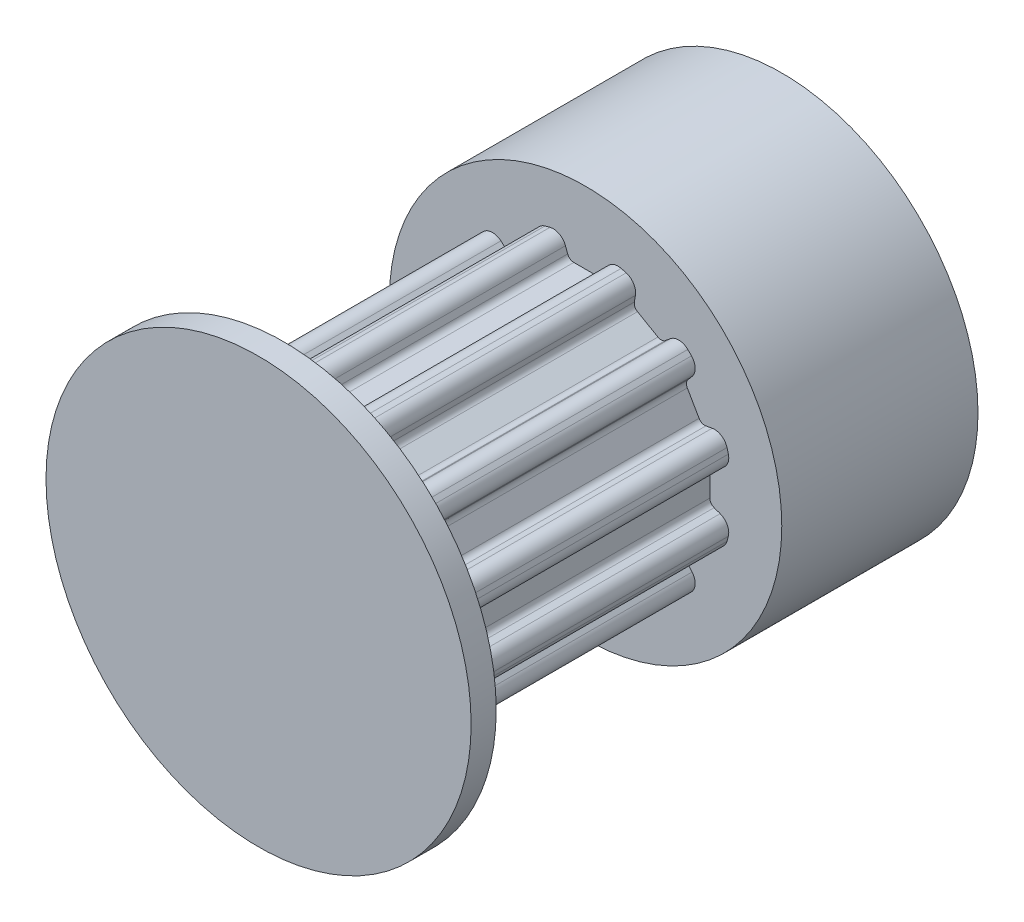
from build123d import *

# Parameters (mm, degrees)
SKETCH5_W           = 10
SKETCH5_H           = 4.5
SKETCH16_W          = 6
SKETCH16_H          = 6
CUT_TOOTH_DEPTH     = 10
PATTERN_TOOTH_COUNT = 12


with BuildPart() as part:
    # Sketch5 → body (revolve)
    with BuildSketch(Plane(origin=(0, 0, 0), x_dir=(0, 0, -1), z_dir=(1, 0, 0))):
        with Locations((5, 2.25)):
            Rectangle(SKETCH5_W, SKETCH5_H)
    revolve(axis=Axis((0, 0, 0), (0, 0, -1)))

    # Sketch16 → body-hub (revolve)
    with BuildSketch(Plane(origin=(0, 0, 0), x_dir=(0, 0, -1), z_dir=(1, 0, 0))):
        with Locations((13, 3)):
            Rectangle(SKETCH16_W, SKETCH16_H)
    revolve(axis=Axis((0, 0, -16), (0, 0, 1)))

    # Sketch23 → cut-tooth (cut)
    with BuildSketch(Plane.XY):
        with BuildLine():
            Line((0.547897017, 3.931595971), (0.6147699, 4.11532771))
            ThreePointArc((0.6147699, 4.11532771), (0.802803604, 4.331669589), (1.087295431, 4.366667911))
            Line((1.087295431, 4.366667911), (1.087295431, 4.933335822))
            Line((1.087295431, 4.933335822), (-1.087295431, 4.933335822))
            Line((-1.087295431, 4.933335822), (-1.087295431, 4.366667911))
            ThreePointArc((-1.087295431, 4.366667911), (-0.802803604, 4.331669589), (-0.6147699, 4.11532771))
            Line((-0.6147699, 4.11532771), (-0.547897017, 3.931595971))
            ThreePointArc((-0.547897017, 3.931595971), (-0.47467378, 3.836169591), (-0.359958492, 3.8))
            Line((-0.359958492, 3.8), (0.359958492, 3.8))
            ThreePointArc((0.359958492, 3.8), (0.47467378, 3.836169591), (0.547897017, 3.931595971))
        make_face()
    cut_tooth = extrude(amount=-CUT_TOOTH_DEPTH, mode=Mode.SUBTRACT)

    # pattern-tooth: cut-tooth ×12 about axis
    pattern_tooth_axis = Axis((0, 0, -10), (0, 0, 1))
    for i in range(1, PATTERN_TOOTH_COUNT):
        add(cut_tooth.rotate(pattern_tooth_axis, i * 360 / PATTERN_TOOTH_COUNT), mode=Mode.SUBTRACT)

    # Sketch25 → body-flange-front (revolve)
    with BuildSketch(Plane(origin=(0, 0, 0), x_dir=(0, 0, -1), z_dir=(1, 0, 0))):
        Polygon((1, 3.25), (0, 3.25), (0, 5.416666667), (0, 6.5), (1, 6.5), (1, 5.416666667), align=None)
    revolve(axis=Axis((0, 0, 0), (0, 0, -1)))

    # Sketch28 → body-flange-profile-front (revolve, cut)
    with BuildSketch(Plane(origin=(0, 0, 0), x_dir=(0, 0, -1), z_dir=(1, 0, 0))):
        Polygon((1, 6.5), (1, 6), (0.766846171, 6.5), align=None)
    revolve(axis=Axis((0, 0, -10), (0, 0, 1)), mode=Mode.SUBTRACT)


solid = part.part
